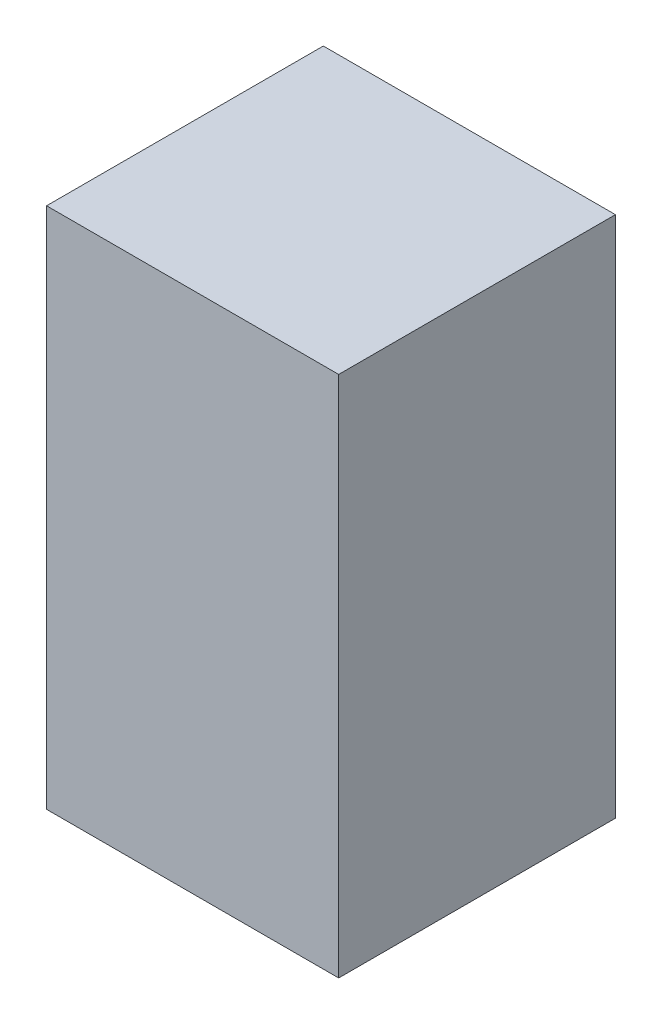
from build123d import *

# Parameters (mm, degrees)
SKETCH1_W           = 0.95000064
SKETCH1_H           = 1.70000168
BOSS_EXTRUDE1_DEPTH = 0.90000074


with BuildPart() as part:
    # Sketch1 → Boss-Extrude1 (new body)
    with BuildSketch(Plane(origin=(0, 0, 0), x_dir=(-1, 0, 0), z_dir=(0, 0, -1))):
        Rectangle(SKETCH1_W, SKETCH1_H)
    extrude(amount=-BOSS_EXTRUDE1_DEPTH)


solid = part.part
